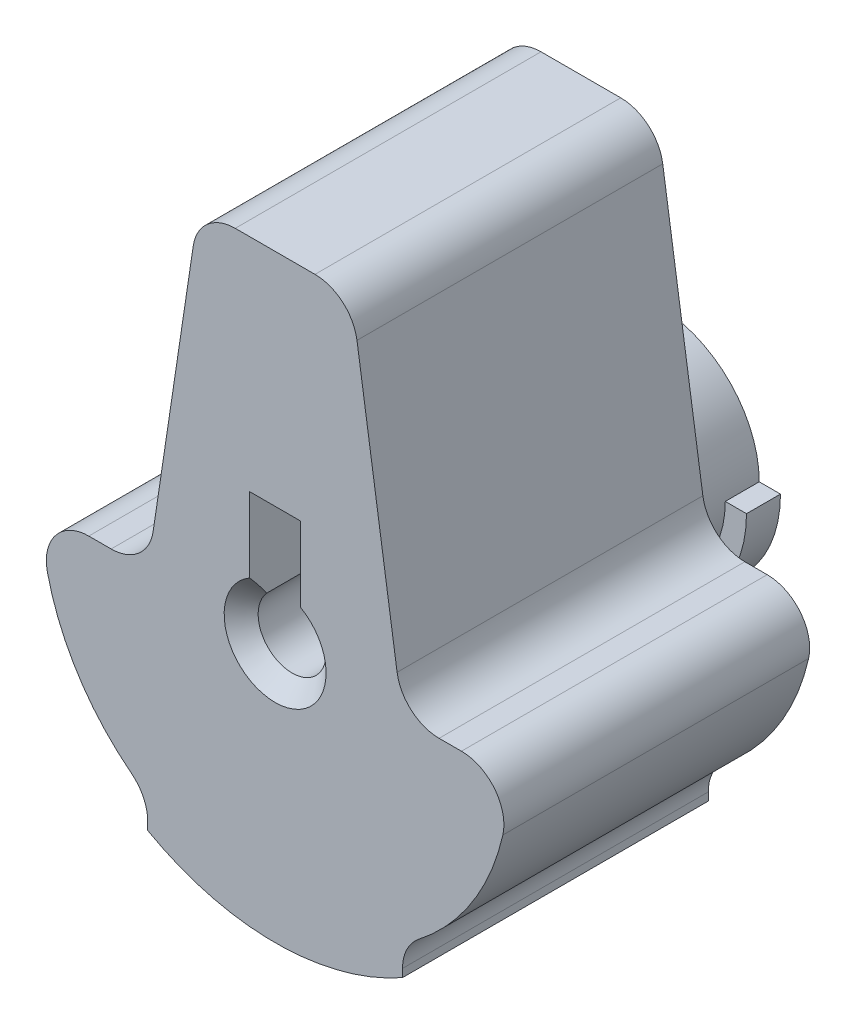
from build123d import *

# Parameters (mm, degrees)
BOSS_EXTRUDE2_DEPTH  = 9.144
CUT_EXTRUDE1_DEPTH   = 0.508
SKETCH4_W            = 1.524
SKETCH4_H            = 3.556
CUT_EXTRUDE2_DEPTH   = 10.144
BOSS_EXTRUDE8_DEPTH  = 9.144
BOSS_EXTRUDE10_DEPTH = 9.144
FILLET2_R            = 1.27
CUT_EXTRUDE4_DEPTH   = 9.144
FILLET4_R            = 1.27
BOSS_EXTRUDE11_DEPTH = 1.27
BOSS_EXTRUDE12_DEPTH = 1.016
BOSS_EXTRUDE13_START = -0.508
BOSS_EXTRUDE13_DEPTH = 0.508
BOSS_EXTRUDE14_DEPTH = 1.27
BOSS_EXTRUDE15_DEPTH = 1.016


with BuildPart() as part:
    # Sketch2 → Boss-Extrude2 (new body)
    with BuildSketch(Plane.XY):
        with BuildLine():
            ThreePointArc((-3.81, 0), (0, -3.81), (3.81, 0))
            Line((3.81, 0), (3.81, 8.636))
            ThreePointArc((3.81, 8.636), (3.363630735, 9.713630735), (2.286, 10.16))
            Line((2.286, 10.16), (-2.286, 10.16))
            ThreePointArc((-2.286, 10.16), (-3.363630735, 9.713630735), (-3.81, 8.636))
            Line((-3.81, 8.636), (-3.81, 0))
        make_face()
        with BuildLine():
            Line((-0.762, 0), (1.016, 0))
            ThreePointArc((1.016, 0), (-0.359210245, -0.950380976), (-0.762, 0.672020833))
            Line((-0.762, 0.672020833), (-0.762, 0))
        make_face(mode=Mode.SUBTRACT)
    extrude(amount=BOSS_EXTRUDE2_DEPTH)

    # Sketch3 → Cut-Extrude1 (cut)
    with BuildSketch(Plane.XY.offset(9.144)):
        with BuildLine():
            Line((-0.762, 0), (1.016, 0))
            ThreePointArc((1.016, 0), (0.950380976, 0.359210245), (0.762, 0.672020833))
            Line((0.762, 0.672020833), (0.762, 3.556))
            Line((0.762, 3.556), (-0.762, 3.556))
            Line((-0.762, 3.556), (-0.762, 0))
        make_face()
    extrude(amount=-CUT_EXTRUDE1_DEPTH, mode=Mode.SUBTRACT)

    # Sketch4 → Cut-Extrude2 (cut, through all)
    with BuildSketch(Plane(origin=(0, 0, 0), x_dir=(-1, 0, 0), z_dir=(0, 0, -1))):
        with Locations((0, 1.778)):
            Rectangle(SKETCH4_W, SKETCH4_H)
    extrude(amount=-CUT_EXTRUDE2_DEPTH, mode=Mode.SUBTRACT)

    # Sketch7 → Cut-Revolve1 (revolve, cut)
    with BuildSketch(Plane(origin=(0, 0, 0), x_dir=(1, 0, 0), z_dir=(0, 1, 0))):
        Polygon((0, 0), (0, -9.144), (1.524, -9.144), (1.016, -8.636), (1.016, -0.508), (1.524, 0), align=None)
    revolve(axis=Axis((0, 0, 0), (0, 0, 1)), mode=Mode.SUBTRACT)

    # Sketch10 → Boss-Extrude8 (add)
    with BuildSketch(Plane.XY.offset(9.144)):
        with BuildLine():
            Line((-3.81, 0), (-6.985, 0))
            ThreePointArc((-6.985, 0), (0, -6.985), (6.985, 0))
            Line((6.985, 0), (3.81, 0))
            ThreePointArc((3.81, 0), (0, -3.81), (-3.81, 0))
        make_face()
    extrude(amount=-BOSS_EXTRUDE8_DEPTH)

    # Sketch14 → Boss-Extrude10 (add)
    with BuildSketch(Plane.XY.offset(9.144)):
        with BuildLine():
            ThreePointArc((3.81, -5.85441073), (0, -6.985), (-3.81, -5.85441073))
            Line((-3.81, -5.85441073), (-3.81, -6.745362036))
            ThreePointArc((-3.81, -6.745362036), (0, -7.747), (3.81, -6.745362036))
            Line((3.81, -6.745362036), (3.81, -5.85441073))
        make_face()
    extrude(amount=-BOSS_EXTRUDE10_DEPTH)

    # Fillet2
    fillet2_edges = [part.edges().sort_by_distance(p)[0] for p in [
        (6.985, 0, 4.572),
        (-6.985, 0, 4.572),
    ]]
    fillet(fillet2_edges, radius=FILLET2_R)

    # Sketch16 → Cut-Extrude4 (cut)
    with BuildSketch(Plane.XY.offset(9.144)):
        with BuildLine():
            Line((-3.81, 0), (-2.286, 10.16))
            ThreePointArc((-2.286, 10.16), (-3.363630735, 9.713630735), (-3.81, 8.636))
            Line((-3.81, 8.636), (-3.81, 0))
        make_face()
        with BuildLine():
            Line((2.286, 10.16), (3.81, 0))
            Line((3.81, 0), (3.81, 8.636))
            ThreePointArc((3.81, 8.636), (3.363630735, 9.713630735), (2.286, 10.16))
        make_face()
    extrude(amount=-CUT_EXTRUDE4_DEPTH, mode=Mode.SUBTRACT)

    # Fillet4
    fillet4_edges = [part.edges().sort_by_distance(p)[0] for p in [
        (-3.81, -5.85441073, 4.572),
        (3.81, -5.85441073, 4.572),
        (-3.81, 0, 4.572),
        (-2.286, 10.16, 4.572),
        (2.286, 10.16, 4.572),
        (3.81, 0, 4.572),
    ]]
    fillet(fillet4_edges, radius=FILLET4_R)

    # Sketch17 → Boss-Extrude11 (add)
    with BuildSketch(Plane(origin=(0, 0, 0), x_dir=(-1, 0, 0), z_dir=(0, 0, -1))):
        with BuildLine():
            Line((0.762, 2.95121331), (0.762, 1.319822715))
            ThreePointArc((0.762, 1.319822715), (0, -1.524), (-0.762, 1.319822715))
            Line((-0.762, 1.319822715), (-0.762, 2.95121331))
            ThreePointArc((-0.762, 2.95121331), (-1.866511184, -2.409655577), (3.048, 0))
            ThreePointArc((3.048, 0), (2.409655577, 1.866511184), (0.762, 2.95121331))
        make_face()
    extrude(amount=BOSS_EXTRUDE11_DEPTH)

    # Sketch18 → Boss-Extrude12 (add)
    with BuildSketch(Plane(origin=(0, 0, -1.27), x_dir=(-1, 0, 0), z_dir=(0, 0, -1))):
        with BuildLine():
            Line((-1.524, 0), (-3.048, 0))
            ThreePointArc((-3.048, 0), (0, -3.048), (3.048, 0))
            Line((3.048, 0), (1.524, 0))
            ThreePointArc((1.524, 0), (0, -1.524), (-1.524, 0))
        make_face()
        with BuildLine():
            Line((-3.048, 0), (-3.683, 0))
            ThreePointArc((-3.683, 0), (0, -3.683), (3.683, 0))
            Line((3.683, 0), (3.048, 0))
            ThreePointArc((3.048, 0), (0, -3.048), (-3.048, 0))
        make_face()
    extrude(amount=BOSS_EXTRUDE12_DEPTH)

    # Sketch20 → Boss-Extrude13 (add)
    with BuildSketch(Plane(origin=(0, 0, 0), x_dir=(-1, 0, 0), z_dir=(0, 0, -1)).offset(BOSS_EXTRUDE13_START)):
        with BuildLine():
            Line((0.762, 1.319822715), (0.762, 0.672020833))
            ThreePointArc((0.762, 0.672020833), (0, -1.016), (-0.762, 0.672020833))
            Line((-0.762, 0.672020833), (-0.762, 1.319822715))
            ThreePointArc((-0.762, 1.319822715), (0, -1.524), (0.762, 1.319822715))
        make_face()
    extrude(amount=BOSS_EXTRUDE13_DEPTH)

    # Sketch21 → Boss-Extrude14 (add)
    with BuildSketch(Plane(origin=(0, 0, 0), x_dir=(-1, 0, 0), z_dir=(0, 0, -1))):
        with BuildLine():
            Line((0.762, 1.319822715), (0.762, 0.672020833))
            ThreePointArc((0.762, 0.672020833), (0, -1.016), (-0.762, 0.672020833))
            Line((-0.762, 0.672020833), (-0.762, 1.319822715))
            ThreePointArc((-0.762, 1.319822715), (0, -1.524), (0.762, 1.319822715))
        make_face()
    extrude(amount=BOSS_EXTRUDE14_DEPTH)

    # Sketch22 → Boss-Extrude15 (add)
    with BuildSketch(Plane(origin=(0, 0, -1.27), x_dir=(-1, 0, 0), z_dir=(0, 0, -1))):
        with BuildLine():
            Line((0.762, 2.95121331), (0.762, 0.672020833))
            ThreePointArc((0.762, 0.672020833), (0, -1.016), (-0.762, 0.672020833))
            Line((-0.762, 0.672020833), (-0.762, 2.95121331))
            ThreePointArc((-0.762, 2.95121331), (-2.409655577, 1.866511184), (-3.048, 0))
            Line((-3.048, 0), (-1.524, 0))
            ThreePointArc((-1.524, 0), (0, -1.524), (1.524, 0))
            Line((1.524, 0), (3.048, 0))
            ThreePointArc((3.048, 0), (2.409655577, 1.866511184), (0.762, 2.95121331))
        make_face()
    extrude(amount=BOSS_EXTRUDE15_DEPTH)

    # Sketch23 → Cut-Revolve2 (revolve, cut)
    with BuildSketch(Plane(origin=(0, 0, 0), x_dir=(1, 0, 0), z_dir=(0, 1, 0))):
        Polygon((0, 2.286), (0, 0), (0.762, 0), (0.762, 1.524), (1.524, 2.286), align=None)
    revolve(axis=Axis((0, 0, -2.286), (0, 0, 1)), mode=Mode.SUBTRACT)


solid = part.part
